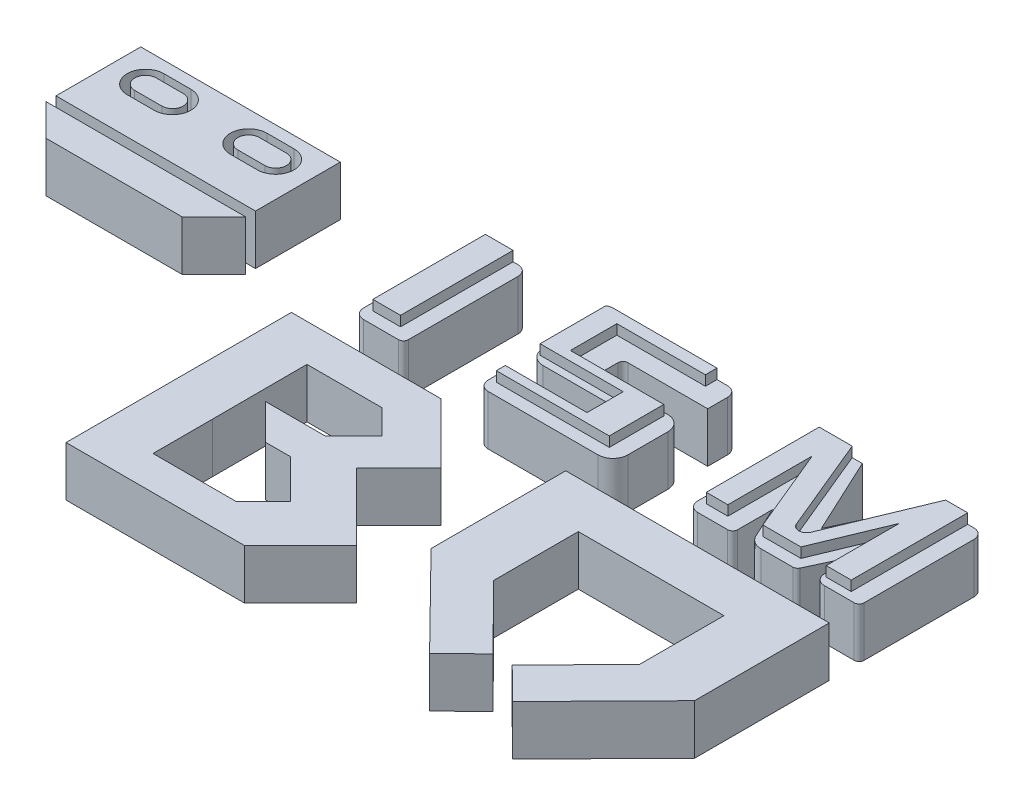
from build123d import *

# Parameters (mm, degrees)
BOSS_EXTRUDE1_DEPTH   = 10
BOSS_EXTRUDE1_2_DEPTH = 10
BOSS_EXTRUDE1_3_DEPTH = 10
BOSS_EXTRUDE1_4_DEPTH = 10
SKETCH2_W             = 10
SKETCH2_H             = 25
BOSS_EXTRUDE1_5_DEPTH = 10
BOSS_EXTRUDE1_6_DEPTH = 10
SKETCH2_W_2           = 40
SKETCH2_H_2           = 17
BOSS_EXTRUDE1_7_DEPTH = 10
BOSS_EXTRUDE1_8_DEPTH = 10
BOSS_EXTRUDE1_9_DEPTH = 10
SKETCH3_W             = 5.552922641
SKETCH3_H             = 22.573169384
BOSS_EXTRUDE2_DEPTH   = 2
BOSS_EXTRUDE3_DEPTH   = 2
BOSS_EXTRUDE4_DEPTH   = 2
FILLET1_R             = 3
FILLET2_R             = 2
FILLET3_R             = 3
FILLET4_R             = 1
FILLET5_R             = 3
FILLET6_R             = 2
FILLET7_R             = 1
FILLET8_R             = 2
FILLET9_R             = 2
FILLET10_R            = 1


with BuildPart() as part:
    # Sketch2 → Boss-Extrude1 (new body)
    with BuildSketch(Plane(origin=(0, 0, 0), x_dir=(1, 0, 0), z_dir=(0, 1, 0))):
        Polygon((8.507188085, -21.536984564), (-27.230698714, -21.536984564), (-27.230698714, 23.643015436), (2.769301286, 23.643015436), (14.792005366, 11.624089252), (6.308057472, 3.137474608), (19.745197326, -10.295442892), align=None)
        Polygon((5.490159492, -9.277894373), (0.038625294, -14.729428571), (-16.608, -14.729428571), (-16.608, -2.796857143), (-16.651976131, 16.17794975), (-1.651976131, 16.17794975), (3.297771337, 11.228202282), (-2.359082913, 5.571348032), (-14.359082913, 5.571348032), (-7.288015101, -1.49971978), (-2.288015101, -1.49971978), align=None, mode=Mode.SUBTRACT)
    extrude(amount=BOSS_EXTRUDE1_DEPTH)


with BuildPart() as body_2:
    # Sketch2 → Boss-Extrude1 2 (new body)
    with BuildSketch(Plane(origin=(0, 0, 0), x_dir=(1, 0, 0), z_dir=(0, 1, 0))):
        Polygon((52.268367855, -15.424806221), (39.584301286, -2.653179258), (39.584301286, 14.346820742), (68.784301286, 14.346820742), (68.784301286, -2.653179258), (56.100234718, -15.424806221), (62.515689668, -21.736853256), (80.599301286, -3.356984564), (80.599301286, 23.643015436), (27.769301286, 23.643015436), (27.769301286, -3.356984564), (45.852912904, -21.736853256), align=None)
    extrude(amount=BOSS_EXTRUDE1_2_DEPTH)


with BuildPart() as body_3:
    # Sketch2 → Boss-Extrude1 3 (new body)
    with BuildSketch(Plane(origin=(0, 0, 0), x_dir=(1, 0, 0), z_dir=(0, 1, 0))):
        Polygon((71.599301286, 29.643015436), (80.599301286, 29.643015436), (80.599301286, 54.643015436), (70.599301286, 54.643015436), (63.414790837, 39.235783056), (56.230280387, 54.643015436), (46.230280387, 54.643015436), (46.230280387, 29.643015436), (55.230280387, 29.643015436), (55.230280387, 37.643015436), (58.943621004, 29.679730786), (63.38596067, 29.679730786), (63.414790837, 29.679730786), (67.88596067, 29.679730786), (71.599301286, 37.643015436), align=None)
    extrude(amount=BOSS_EXTRUDE1_3_DEPTH)

    # Sketch5 → Boss-Extrude4 (add)
    with BuildSketch(Plane(origin=(0, 10, 0), x_dir=(1, 0, 0), z_dir=(0, 1, 0))):
        with BuildLine():
            Line((47.589769515, 31.999354556), (47.589769515, 54.643015436))
            Line((47.589769515, 54.643015436), (54.206017768, 54.643015436))
            Line((54.206017768, 54.643015436), (62.121886213, 35.543773263))
            ThreePointArc((62.121886213, 35.543773263), (63.569190519, 34.576935425), (65.016494824, 35.543773263))
            Line((65.016494824, 35.543773263), (72.93236327, 54.643015436))
            Line((72.93236327, 54.643015436), (77.362886653, 54.643015436))
            Line((77.362886653, 54.643015436), (77.362886653, 31.290470814))
            Line((77.362886653, 31.290470814), (72.341626818, 31.290470814))
            Line((72.341626818, 31.290470814), (72.341626818, 45.940734803))
            Line((72.341626818, 45.940734803), (66.563484891, 31.999354556))
            Line((66.563484891, 31.999354556), (58.931909377, 31.999354556))
            Line((58.931909377, 31.999354556), (51.911817177, 48.9372865))
            Line((51.911817177, 48.9372865), (51.911817177, 31.999354556))
            Line((51.911817177, 31.999354556), (47.589769515, 31.999354556))
        make_face()
    extrude(amount=BOSS_EXTRUDE4_DEPTH)

    # Fillet5
    fillet5_edges = [body_3.edges().sort_by_distance(p)[0] for p in [
        (58.943621004, 5, -29.679730786),
    ]]
    fillet(fillet5_edges, radius=FILLET5_R)

    # Fillet6
    fillet6_edges = [body_3.edges().sort_by_distance(p)[0] for p in [
        (80.599301286, 5, -54.643015436),
        (71.599301286, 5, -29.643015436),
        (46.230280387, 5, -29.643015436),
    ]]
    fillet(fillet6_edges, radius=FILLET6_R)

    # Fillet7
    fillet7_edges = [body_3.edges().sort_by_distance(p)[0] for p in [
        (80.599301286, 5, -29.643015436),
        (67.88596067, 5, -29.679730786),
        (55.230280387, 5, -29.643015436),
        (46.230280387, 5, -54.643015436),
    ]]
    fillet(fillet7_edges, radius=FILLET7_R)


with BuildPart() as body_4:
    # Sketch2 → Boss-Extrude1 4 (new body)
    with BuildSketch(Plane(origin=(0, 0, 0), x_dir=(1, 0, 0), z_dir=(0, 1, 0))):
        Polygon((4.230280387, 29.643015436), (31.230280387, 29.643015436), (31.230280387, 43.643015436), (14.230280387, 43.643015436), (14.230280387, 48.643015436), (31.230280387, 48.643015436), (31.230280387, 54.643015436), (4.230280387, 54.643015436), (4.230280387, 39.643015436), (21.230280387, 39.643015436), (21.230280387, 34.643015436), (4.230280387, 34.643015436), align=None)
    extrude(amount=BOSS_EXTRUDE1_4_DEPTH)

    # Sketch4 → Boss-Extrude3 (add)
    with BuildSketch(Plane(origin=(0, 10, 0), x_dir=(1, 0, 0), z_dir=(0, 1, 0))):
        Polygon((27.097094219, 54.643015436), (27.097094219, 52.313601998), (9.347826807, 52.313601998), (9.347826807, 42.997688163), (28.077716728, 42.997688163), (28.077716728, 32.063747189), (5.425336772, 32.063747189), (5.425336772, 33.87789883), (21.801732671, 33.87789883), (21.801732671, 41.134505396), (5.131150019, 41.134505396), (5.131150019, 54.643015436), align=None)
    extrude(amount=BOSS_EXTRUDE3_DEPTH)

    # Fillet1
    fillet1_edges = [body_4.edges().sort_by_distance(p)[0] for p in [
        (31.230280387, 5, -43.643015436),
        (31.230280387, 5, -29.643015436),
    ]]
    fillet(fillet1_edges, radius=FILLET1_R)

    # Fillet2
    fillet2_edges = [body_4.edges().sort_by_distance(p)[0] for p in [
        (4.230280387, 5, -54.643015436),
        (4.230280387, 5, -29.643015436),
        (31.230280387, 5, -54.643015436),
    ]]
    fillet(fillet2_edges, radius=FILLET2_R)

    # Fillet3
    fillet3_edges = [body_4.edges().sort_by_distance(p)[0] for p in [
        (4.230280387, 5, -39.643015436),
    ]]
    fillet(fillet3_edges, radius=FILLET3_R)

    # Fillet4
    fillet4_edges = [body_4.edges().sort_by_distance(p)[0] for p in [
        (21.230280387, 5, -34.643015436),
        (21.230280387, 5, -39.643015436),
        (14.230280387, 5, -48.643015436),
        (14.230280387, 5, -43.643015436),
    ]]
    fillet(fillet4_edges, radius=FILLET4_R)


with BuildPart() as body_5:
    # Sketch2 → Boss-Extrude1 5 (new body)
    with BuildSketch(Plane(origin=(0, 0, 0), x_dir=(1, 0, 0), z_dir=(0, 1, 0))):
        with Locations((-15.769719613, 42.143015436)):
            Rectangle(SKETCH2_W, SKETCH2_H)
    extrude(amount=BOSS_EXTRUDE1_5_DEPTH)

    # Sketch3 → Boss-Extrude2 (add)
    with BuildSketch(Plane(origin=(0, 10, 0), x_dir=(1, 0, 0), z_dir=(0, 1, 0))):
        with Locations((-16.559233642, 43.356430744)):
            Rectangle(SKETCH3_W, SKETCH3_H)
    extrude(amount=BOSS_EXTRUDE2_DEPTH)

    # Fillet8
    fillet8_edges = [body_5.edges().sort_by_distance(p)[0] for p in [
        (-20.769719613, 5, -29.643015436),
    ]]
    fillet(fillet8_edges, radius=FILLET8_R)

    # Fillet9
    fillet9_edges = [body_5.edges().sort_by_distance(p)[0] for p in [
        (-10.769719613, 5, -54.643015436),
    ]]
    fillet(fillet9_edges, radius=FILLET9_R)

    # Fillet10
    fillet10_edges = [body_5.edges().sort_by_distance(p)[0] for p in [
        (-10.769719613, 5, -29.643015436),
        (-20.769719613, 5, -54.643015436),
    ]]
    fillet(fillet10_edges, radius=FILLET10_R)


with BuildPart() as body_6:
    # Sketch2 → Boss-Extrude1 6 (new body)
    with BuildSketch(Plane(origin=(0, 0, 0), x_dir=(1, 0, 0), z_dir=(0, 1, 0))):
        Polygon((-88.431569856, 35.643015436), (-82.067608825, 29.279054405), (-54.795530886, 29.279054405), (-48.431569856, 35.643015436), align=None)
    extrude(amount=BOSS_EXTRUDE1_6_DEPTH)


with BuildPart() as body_7:
    # Sketch2 → Boss-Extrude1 7 (new body)
    with BuildSketch(Plane(origin=(0, 0, 0), x_dir=(1, 0, 0), z_dir=(0, 1, 0))):
        with Locations((-68.431569856, 46.143015436)):
            Rectangle(SKETCH2_W_2, SKETCH2_H_2)
        with BuildLine():
            ThreePointArc((-76.064855636, 44.975142941), (-72.396983141, 48.643015436), (-76.064855636, 52.310887931))
            Line((-76.064855636, 52.310887931), (-81.483826522, 52.310887931))
            ThreePointArc((-81.483826522, 52.310887931), (-85.151699017, 48.643015436), (-81.483826522, 44.975142941))
            Line((-81.483826522, 44.975142941), (-76.064855636, 44.975142941))
        make_face(mode=Mode.SUBTRACT)
        with BuildLine():
            Line((-55.379313189, 44.975142941), (-60.798284075, 44.975142941))
            ThreePointArc((-60.798284075, 44.975142941), (-64.46615657, 48.643015436), (-60.798284075, 52.310887931))
            Line((-60.798284075, 52.310887931), (-55.379313189, 52.310887931))
            ThreePointArc((-55.379313189, 52.310887931), (-51.711440694, 48.643015436), (-55.379313189, 44.975142941))
        make_face(mode=Mode.SUBTRACT)
    extrude(amount=BOSS_EXTRUDE1_7_DEPTH)


with BuildPart() as body_8:
    # Sketch2 → Boss-Extrude1 8 (new body)
    with BuildSketch(Plane(origin=(0, 0, 0), x_dir=(1, 0, 0), z_dir=(0, 1, 0))):
        with BuildLine():
            Line((-81.483826522, 46.483591027), (-76.064855636, 46.483591027))
            ThreePointArc((-76.064855636, 46.483591027), (-73.905431227, 48.643015436), (-76.064855636, 50.802439846))
            Line((-76.064855636, 50.802439846), (-81.483826522, 50.802439846))
            ThreePointArc((-81.483826522, 50.802439846), (-83.643250932, 48.643015436), (-81.483826522, 46.483591027))
        make_face()
    extrude(amount=BOSS_EXTRUDE1_8_DEPTH)


with BuildPart() as body_9:
    # Sketch2 → Boss-Extrude1 9 (new body)
    with BuildSketch(Plane(origin=(0, 0, 0), x_dir=(1, 0, 0), z_dir=(0, 1, 0))):
        with BuildLine():
            ThreePointArc((-60.798284075, 46.483591027), (-62.957708484, 48.643015436), (-60.798284075, 50.802439846))
            Line((-60.798284075, 50.802439846), (-55.379313189, 50.802439846))
            ThreePointArc((-55.379313189, 50.802439846), (-53.21988878, 48.643015436), (-55.379313189, 46.483591027))
            Line((-55.379313189, 46.483591027), (-60.798284075, 46.483591027))
        make_face()
    extrude(amount=BOSS_EXTRUDE1_9_DEPTH)


solid = Compound([part.part, body_2.part, body_3.part, body_4.part, body_5.part, body_6.part, body_7.part, body_8.part, body_9.part])
